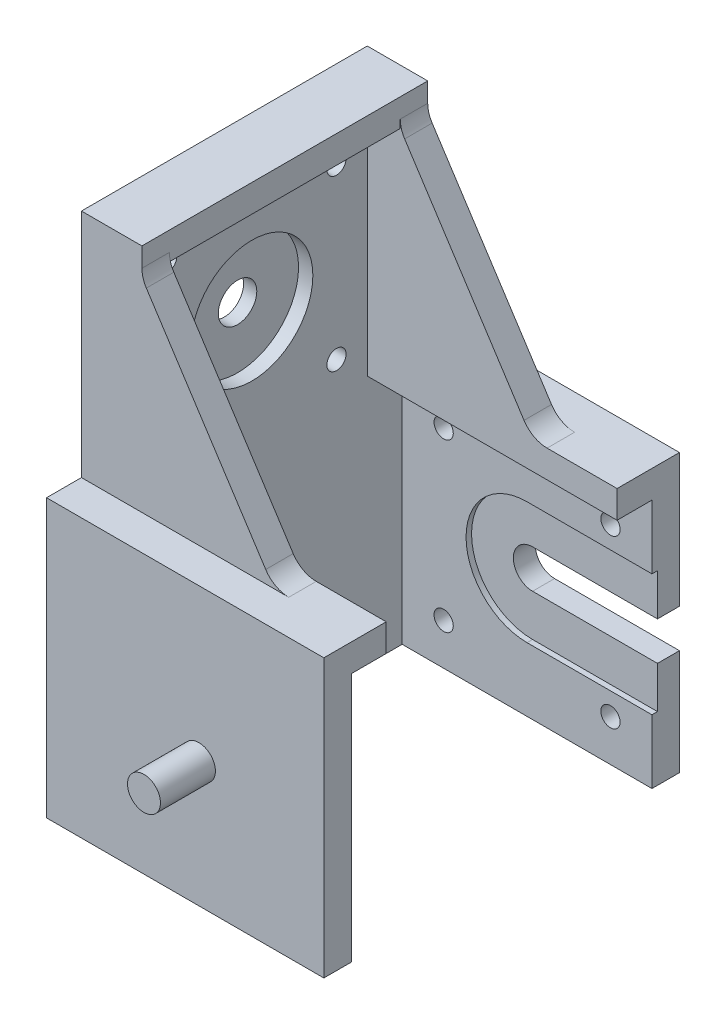
from build123d import *

# Parameters (mm, degrees)
BOSS_EXTRUDE1_DEPTH = 45.45
CUT_EXTRUDE4_DEPTH  = 1
CUT_EXTRUDE5_DEPTH  = 5
SKETCH9_R           = 1.75
CUT_EXTRUDE6_DEPTH  = 5
BOSS_EXTRUDE2_DEPTH = 5
SKETCH11_R          = 1.75
SKETCH11_R_2        = 1.715
CUT_EXTRUDE7_DEPTH  = 5
SKETCH13_R          = 3.5
CUT_EXTRUDE8_DEPTH  = 5
SKETCH13_3_R        = 11.1
CUT_EXTRUDE9_DEPTH  = 2.6
SKETCH14_W          = 50.45
SKETCH14_H          = 11.35
BOSS_EXTRUDE3_DEPTH = 5
SKETCH15_W          = 50.45
SKETCH15_H          = 11.35
BOSS_EXTRUDE4_DEPTH = 5
SKETCH17_W          = 42
SKETCH17_H          = 5
BOSS_EXTRUDE5_DEPTH = 11
BOSS_EXTRUDE6_DEPTH = 5
BOSS_EXTRUDE7_DEPTH = 5
SKETCH21_R          = 3
BOSS_EXTRUDE8_DEPTH = 15
FILLET1_R           = 5
FILLET2_R           = 5


with BuildPart() as part:
    # Sketch1 → Boss-Extrude1 (new body)
    with BuildSketch(Plane(origin=(0, 0, 0), x_dir=(1, 0, 0), z_dir=(0, 1, 0))):
        Polygon((22.725, 27.35), (22.725, 32.35), (-22.725, 32.35), (-27.725, 32.35), (-27.725, -27.35), (-27.725, -32.35), (22.725, -32.35), (22.725, -27.35), (-22.725, -27.35), (-22.725, 27.35), (0, 27.35), align=None)
    extrude(amount=BOSS_EXTRUDE1_DEPTH)

    # Sketch5 → Cut-Extrude4 (cut)
    with BuildSketch(Plane.XY.offset(-27.35)):
        with BuildLine():
            Line((0, 33.825), (22.725, 33.825))
            Line((22.725, 33.825), (22.725, 11.625))
            Line((22.725, 11.625), (0, 11.625))
            ThreePointArc((0, 11.625), (-11.1, 22.725), (0, 33.825))
        make_face()
    extrude(amount=-CUT_EXTRUDE4_DEPTH, mode=Mode.SUBTRACT)

    # Sketch6 → Cut-Extrude5 (cut)
    with BuildSketch(Plane.XY.offset(-27.35)):
        with BuildLine():
            Line((0, 26.225), (22.725, 26.225))
            Line((22.725, 26.225), (22.725, 19.225))
            Line((22.725, 19.225), (0, 19.225))
            ThreePointArc((0, 19.225), (-3.5, 22.725), (0, 26.225))
        make_face()
    extrude(amount=-CUT_EXTRUDE5_DEPTH, mode=Mode.SUBTRACT)

    # Sketch9 → Cut-Extrude6 (cut)
    with BuildSketch(Plane.XY.offset(-27.35)):
        with Locations((15.175, 37.9)):
            Circle(SKETCH9_R)
        with Locations((-15.175, 37.9)):
            Circle(SKETCH9_R)
        with Locations((15.175, 7.55)):
            Circle(SKETCH9_R)
        with Locations((-15.175, 7.55)):
            Circle(SKETCH9_R)
    extrude(amount=-CUT_EXTRUDE6_DEPTH, mode=Mode.SUBTRACT)

    # Sketch10 → Boss-Extrude2 (add)
    with BuildSketch(Plane(origin=(-22.725, 0, 0), x_dir=(0, 0, -1), z_dir=(1, 0, 0))):
        Polygon((0, 45.45), (21, 45.45), (21, 87.45), (-21, 87.45), (-21, 45.45), align=None)
    extrude(amount=-BOSS_EXTRUDE2_DEPTH)

    # Sketch11 → Cut-Extrude7 (cut)
    with BuildSketch(Plane(origin=(-22.725, 0, 0), x_dir=(0, 0, -1), z_dir=(1, 0, 0))):
        with Locations((-15.4, 81.65)):
            Circle(SKETCH11_R)
        with Locations((15.4, 81.65)):
            Circle(SKETCH11_R)
        with Locations((-15.4, 50.85)):
            Circle(SKETCH11_R_2)
        with Locations((15.4, 50.85)):
            Circle(SKETCH11_R)
    extrude(amount=-CUT_EXTRUDE7_DEPTH, mode=Mode.SUBTRACT)

    # Sketch13 → Cut-Extrude8 (cut)
    with BuildSketch(Plane(origin=(-22.725, 0, 0), x_dir=(0, 0, -1), z_dir=(1, 0, 0))):
        with Locations((0, 66.25)):
            Circle(SKETCH13_R)
    extrude(amount=-CUT_EXTRUDE8_DEPTH, mode=Mode.SUBTRACT)

    # Sketch13_3 → Cut-Extrude9 (cut)
    with BuildSketch(Plane(origin=(-22.725, 0, 0), x_dir=(0, 0, -1), z_dir=(1, 0, 0))):
        with Locations((0, 66.25)):
            Circle(SKETCH13_3_R)
    extrude(amount=-CUT_EXTRUDE9_DEPTH, mode=Mode.SUBTRACT)

    # Sketch14 → Boss-Extrude3 (add)
    with BuildSketch(Plane(origin=(0, 45.45, 0), x_dir=(1, 0, 0), z_dir=(0, 1, 0))):
        with Locations((-2.5, 26.675)):
            Rectangle(SKETCH14_W, SKETCH14_H)
    extrude(amount=BOSS_EXTRUDE3_DEPTH)

    # Sketch15 → Boss-Extrude4 (add)
    with BuildSketch(Plane(origin=(0, 45.45, 0), x_dir=(1, 0, 0), z_dir=(0, 1, 0))):
        with Locations((-2.5, -26.675)):
            Rectangle(SKETCH15_W, SKETCH15_H)
    extrude(amount=BOSS_EXTRUDE4_DEPTH)

    # Sketch17 → Boss-Extrude5 (add)
    with BuildSketch(Plane.ZY.offset(27.725)):
        with Locations((0, 89.95)):
            Rectangle(SKETCH17_W, SKETCH17_H)
    extrude(amount=-BOSS_EXTRUDE5_DEPTH)

    # Sketch19 → Boss-Extrude6 (add)
    with BuildSketch(Plane.XY.offset(21)):
        Polygon((-22.725, 50.45), (7.275, 50.45), (-16.725, 87.45), (-16.725, 92.45), (-27.725, 92.45), (-27.725, 50.45), align=None)
    extrude(amount=BOSS_EXTRUDE6_DEPTH)

    # Sketch20 → Boss-Extrude7 (add)
    with BuildSketch(Plane(origin=(0, 0, -21), x_dir=(-1, 0, 0), z_dir=(0, 0, -1))):
        Polygon((22.725, 50.45), (-7.275, 50.45), (16.725, 87.45), (16.725, 92.45), (27.725, 92.45), (27.725, 50.45), align=None)
    extrude(amount=BOSS_EXTRUDE7_DEPTH)

    # Sketch21 → Boss-Extrude8 (add)
    with BuildSketch(Plane(origin=(0, 0, 27.35), x_dir=(-1, 0, 0), z_dir=(0, 0, -1))):
        with Locations((0, 22.725)):
            Circle(SKETCH21_R)
    extrude(amount=-BOSS_EXTRUDE8_DEPTH)

    # Fillet1
    fillet1_edges = [part.edges().sort_by_distance(p)[0] for p in [
        (7.275, 50.45, 23.5),
        (7.275, 50.45, -23.5),
    ]]
    fillet(fillet1_edges, radius=FILLET1_R)

    # Fillet2
    fillet2_edges = [part.edges().sort_by_distance(p)[0] for p in [
        (-16.725, 87.45, 23.5),
        (-16.725, 87.45, -23.5),
    ]]
    fillet(fillet2_edges, radius=FILLET2_R)


solid = part.part
